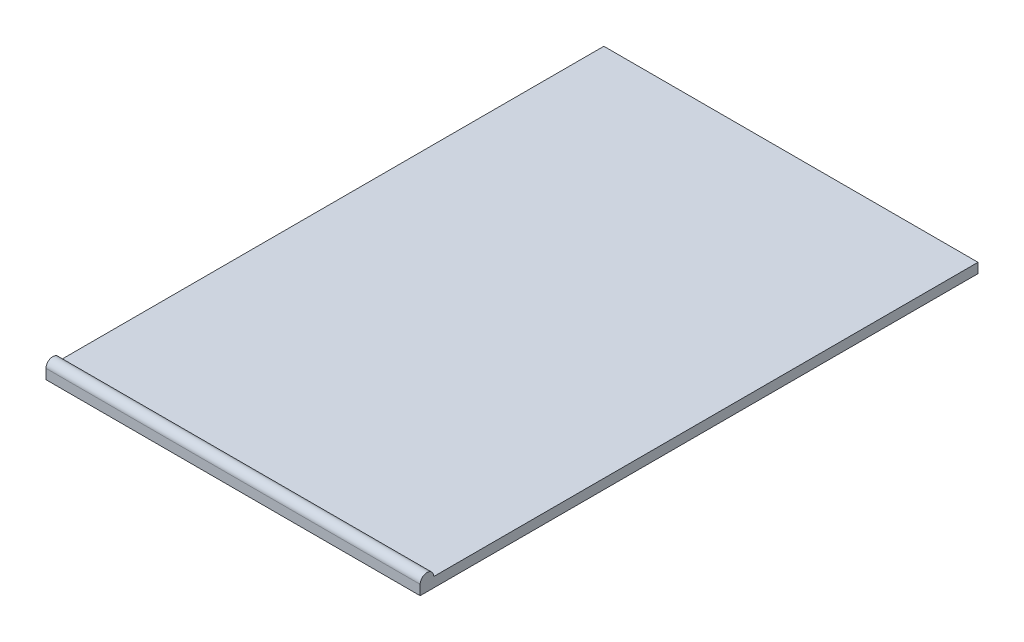
from build123d import *

# Parameters (mm, degrees)
SKETCH1_W           = 110
SKETCH1_H           = 164
BOSS_EXTRUDE1_DEPTH = 2.9
SKETCH2_W           = 110
SKETCH2_H           = 2
REVOLVE1_ANGLE      = 180


with BuildPart() as part:
    # Sketch1 → Boss-Extrude1 (new body)
    with BuildSketch(Plane(origin=(0, 0, 0), x_dir=(1, 0, 0), z_dir=(0, 1, 0))):
        with Locations((55, -82)):
            Rectangle(SKETCH1_W, SKETCH1_H)
    extrude(amount=BOSS_EXTRUDE1_DEPTH)

    # Sketch2 → Revolve1 (revolve)
    with BuildSketch(Plane(origin=(0, 2.9, 0), x_dir=(1, 0, 0), z_dir=(0, 1, 0))):
        with Locations((55, -163)):
            Rectangle(SKETCH2_W, SKETCH2_H)
    revolve(axis=Axis((110, 2.9, 162), (-1, 0, 0)), revolution_arc=REVOLVE1_ANGLE)


solid = part.part
